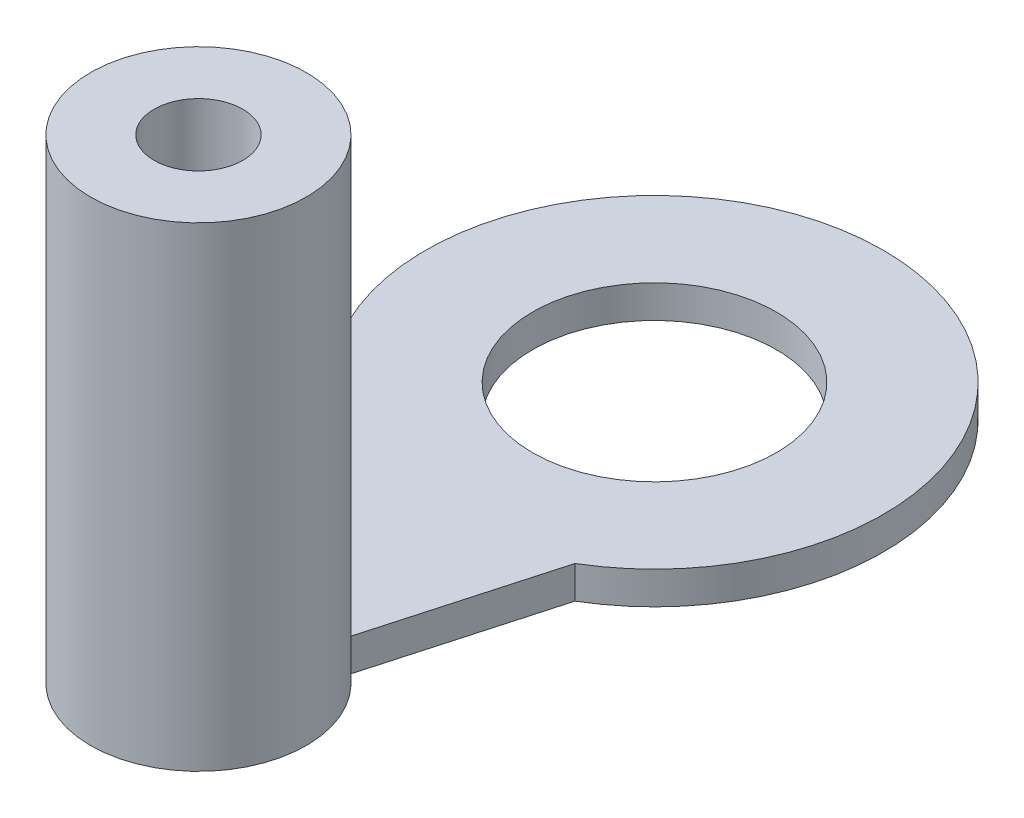
from build123d import *

# Parameters (mm, degrees)
SKETCH1_R                       = 5.96
BOSS_EXTRUDE1_DEPTH             = 0.85
F_1_4_0_25_DIAMETER_HOLE1_D     = 6.35
F_1_4_0_25_DIAMETER_HOLE1_DEPTH = 0.85
SKETCH5_R                       = 2.81
SKETCH5_R_2                     = 1.155
BOSS_EXTRUDE2_DEPTH             = 11.52
BOSS_EXTRUDE2_DEPTH_BACK        = 0.85
BOSS_EXTRUDE3_DEPTH             = 0.85
SKETCH9_R                       = 1.155
CUT_EXTRUDE1_DEPTH              = 1.85


with BuildPart() as part:
    # Sketch1 → Boss-Extrude1 (new body)
    with BuildSketch(Plane(origin=(0, 0, 0), x_dir=(1, 0, 0), z_dir=(0, 1, 0))):
        Circle(SKETCH1_R)
    extrude(amount=BOSS_EXTRUDE1_DEPTH)

    # 1/4 (0.25) Diameter Hole1
    with Locations(Plane(origin=(0, 0.85, 0), x_dir=(1, 0, 0), z_dir=(0, 1, 0))):
        with Locations((0, 0)):
            Hole(F_1_4_0_25_DIAMETER_HOLE1_D / 2, depth=F_1_4_0_25_DIAMETER_HOLE1_DEPTH)



with BuildPart() as body_2:
    # Sketch5 → Boss-Extrude2 (new body, two sides)
    with BuildSketch(Plane(origin=(0, 0.85, 0), x_dir=(1, 0, 0), z_dir=(0, 1, 0))) as boss_extrude2_sk:
        with Locations((0, -11.875)):
            Circle(SKETCH5_R)
        with Locations((0, -11.875)):
            Circle(SKETCH5_R_2, mode=Mode.SUBTRACT)
    extrude(amount=BOSS_EXTRUDE2_DEPTH)
    extrude(boss_extrude2_sk.sketch, amount=-BOSS_EXTRUDE2_DEPTH_BACK)


with BuildPart() as part_1:
    add(part.part)

    add(body_2.part)  # Boss-Extrude3 merges body 2
    # Sketch6 → Boss-Extrude3 (add)
    with BuildSketch(Plane(origin=(0, 0.85, 0), x_dir=(1, 0, 0), z_dir=(0, 1, 0))):
        Polygon((-1.155, -11.875), (-3.036993485, -5.128183945), (3.04994253, -5.120493195), (1.155, -11.875), align=None)
    extrude(amount=-BOSS_EXTRUDE3_DEPTH)

    # Sketch9 → Cut-Extrude1 (cut, through all)
    with BuildSketch(Plane(origin=(0, 0.85, 0), x_dir=(1, 0, 0), z_dir=(0, 1, 0))):
        with Locations((0, -11.875)):
            Circle(SKETCH9_R)
    extrude(amount=-CUT_EXTRUDE1_DEPTH, mode=Mode.SUBTRACT)


solid = part_1.part
